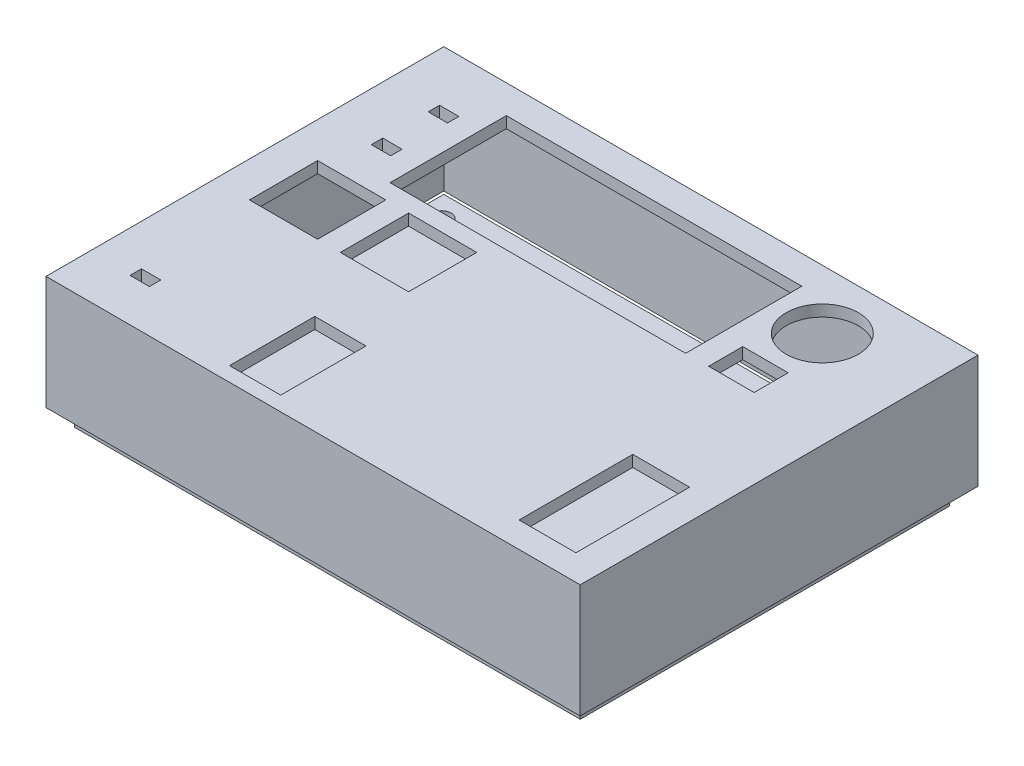
from build123d import *

# Parameters (mm, degrees)
SKETCH1_W                = 94
SKETCH1_H                = 70
SKETCH1_R                = 6.35
SKETCH1_W_2              = 8
SKETCH1_H_2              = 6
SKETCH1_W_3              = 3.4
SKETCH1_H_3              = 2
SKETCH1_W_4              = 52
SKETCH1_H_4              = 20.451642238
SKETCH1_W_5              = 12
SKETCH1_H_5              = 12
SKETCH1_W_6              = 9
SKETCH1_H_6              = 15
SKETCH1_W_7              = 10
SKETCH1_H_7              = 20
BOSS_EXTRUDE1_DEPTH      = 2
SKETCH2_W                = 94
SKETCH2_H                = 70
SKETCH2_W_2              = 90
SKETCH2_H_2              = 66
BOSS_EXTRUDE2_DEPTH      = 1
BOSS_EXTRUDE2_DEPTH_BACK = 18
CUT_EXTRUDE1_START       = -94
SKETCH3_W                = 7
SKETCH3_H                = 5.793277682
CUT_EXTRUDE1_DEPTH       = 10
CUT_EXTRUDE1_DEPTH_BACK  = 10
SKETCH4_W                = 89
SKETCH4_H                = 65
BOSS_EXTRUDE3_DEPTH      = 3
SKETCH5_R                = 1.7
CUT_EXTRUDE5_DEPTH       = 3


with BuildPart() as part:
    # Sketch1 → Boss-Extrude1 (new body)
    with BuildSketch(Plane(origin=(0, 0, 0), x_dir=(1, 0, 0), z_dir=(0, 1, 0))):
        with Locations((-6.75, 10.284411869)):
            Rectangle(SKETCH1_W, SKETCH1_H)
        with Locations((23.25, 34.886908177)):
            Circle(SKETCH1_R, mode=Mode.SUBTRACT)
        with Locations((22.25, 22.886908177)):
            Rectangle(SKETCH1_W_2, SKETCH1_H_2, mode=Mode.SUBTRACT)
        with Locations((-43.5, 24.984411869)):
            Rectangle(SKETCH1_W_3, SKETCH1_H_3, mode=Mode.SUBTRACT)
        with Locations((-11.75, 30.05859075)):
            Rectangle(SKETCH1_W_4, SKETCH1_H_4, mode=Mode.SUBTRACT)
        with Locations((-41.502745427, 10.832769631)):
            Rectangle(SKETCH1_W_5, SKETCH1_H_5, mode=Mode.SUBTRACT)
        with Locations((-25.502745427, 10.832769631)):
            Rectangle(SKETCH1_W_5, SKETCH1_H_5, mode=Mode.SUBTRACT)
        with Locations((-43.5, 34.984411869)):
            Rectangle(SKETCH1_W_3, SKETCH1_H_3, mode=Mode.SUBTRACT)
        with Locations((-19.502745427, -14.667230369)):
            Rectangle(SKETCH1_W_6, SKETCH1_H_6, mode=Mode.SUBTRACT)
        with Locations((29.997254573, -10.215588131)):
            Rectangle(SKETCH1_W_7, SKETCH1_H_7, mode=Mode.SUBTRACT)
        with Locations((-44.802745427, -16.167230369)):
            Rectangle(SKETCH1_W_3, SKETCH1_H_3, mode=Mode.SUBTRACT)
    extrude(amount=BOSS_EXTRUDE1_DEPTH)

    # Sketch2 → Boss-Extrude2 (add, two sides)
    with BuildSketch(Plane(origin=(0, 0, 0), x_dir=(1, 0, 0), z_dir=(0, 1, 0))) as boss_extrude2_sk:
        with Locations((-6.75, 10.284411869)):
            Rectangle(SKETCH2_W, SKETCH2_H)
        with Locations((-6.75, 10.284411869)):
            Rectangle(SKETCH2_W_2, SKETCH2_H_2, mode=Mode.SUBTRACT)
    extrude(amount=BOSS_EXTRUDE2_DEPTH)
    extrude(boss_extrude2_sk.sketch, amount=-BOSS_EXTRUDE2_DEPTH_BACK)

    # Sketch3 → Cut-Extrude1 (cut, two sides)
    with BuildSketch(Plane(origin=(40.25, 0, 0), x_dir=(0, 0, -1), z_dir=(1, 0, 0)).offset(CUT_EXTRUDE1_START)) as cut_extrude1_sk:
        with Locations((-10.515588131, -3.896638841)):
            Rectangle(SKETCH3_W, SKETCH3_H)
    extrude(amount=CUT_EXTRUDE1_DEPTH, mode=Mode.SUBTRACT)
    extrude(cut_extrude1_sk.sketch, amount=-CUT_EXTRUDE1_DEPTH_BACK, mode=Mode.SUBTRACT)


with BuildPart() as body_2:
    # Sketch4 → Boss-Extrude3 (new body)
    with BuildSketch(Plane.XZ.offset(18)):
        with Locations((-6.75, -10.284411869)):
            Rectangle(SKETCH4_W, SKETCH4_H)
    extrude(amount=BOSS_EXTRUDE3_DEPTH)

    # Sketch5 → Cut-Extrude5 (cut)
    with BuildSketch(Plane(origin=(0, -21, 0), x_dir=(-1, 0, 0), z_dir=(0, -1, 0))):
        with Locations((-34.75, 39.784411869)):
            Circle(SKETCH5_R)
        with Locations((35.25, -15.115588131)):
            Circle(SKETCH5_R)
        with Locations((47.75, 38.884411869)):
            Circle(SKETCH5_R)
    extrude(amount=-CUT_EXTRUDE5_DEPTH, mode=Mode.SUBTRACT)


solid = Compound([part.part, body_2.part])
